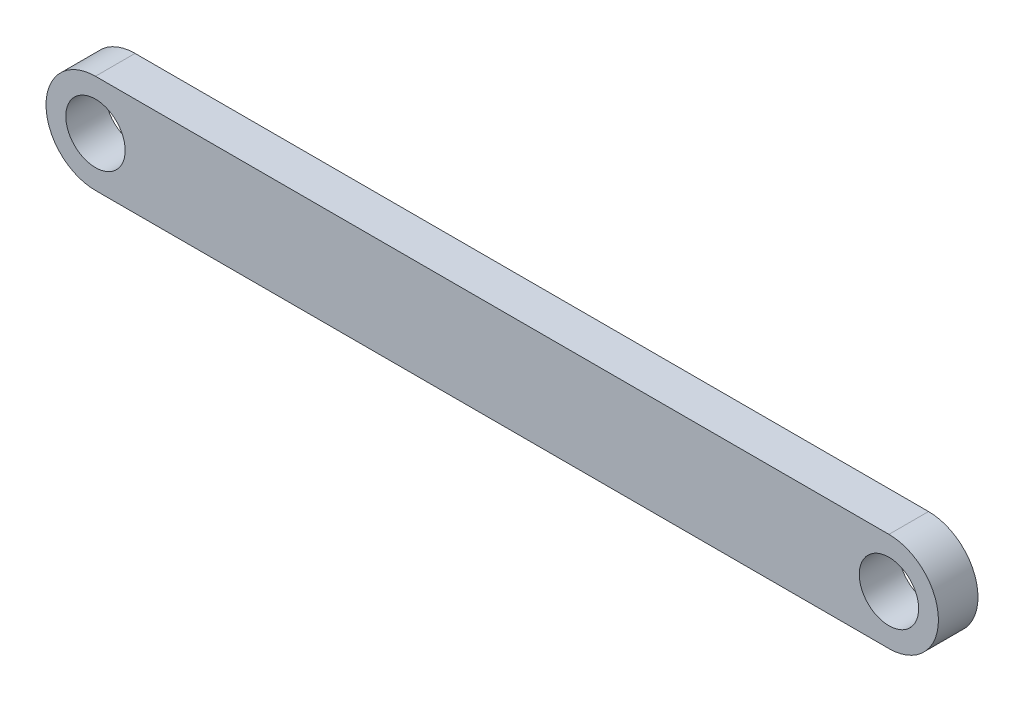
from build123d import *

# Parameters (mm, degrees)
SKETCH1_R           = 1.5
BOSS_EXTRUDE1_DEPTH = 2


with BuildPart() as part:
    # Sketch1 → Boss-Extrude1 (new body)
    with BuildSketch(Plane.XY):
        with BuildLine():
            Line((0.144561732, 2.42726269), (40.244561732, 2.42726269))
            ThreePointArc((40.244561732, 2.42726269), (42.744561732, -0.07273731), (40.244561732, -2.57273731))
            Line((40.244561732, -2.57273731), (0.144561732, -2.57273731))
            ThreePointArc((0.144561732, -2.57273731), (-2.355438268, -0.07273731), (0.144561732, 2.42726269))
        make_face()
        with Locations((0.144561732, -0.07273731)):
            Circle(SKETCH1_R, mode=Mode.SUBTRACT)
        with Locations((40.244561732, -0.07273731)):
            Circle(SKETCH1_R, mode=Mode.SUBTRACT)
    extrude(amount=BOSS_EXTRUDE1_DEPTH)


solid = part.part
